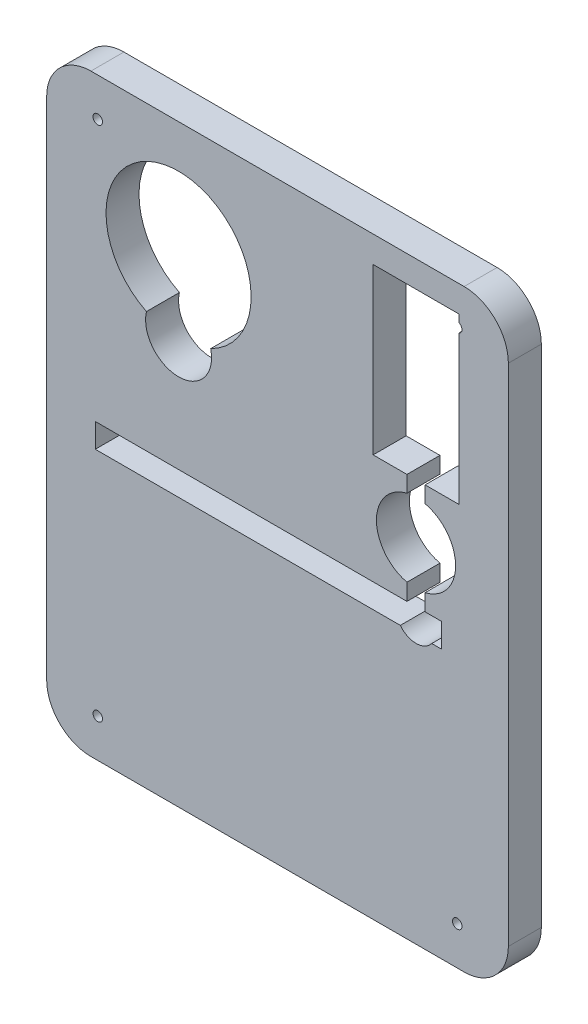
from build123d import *

# Parameters (mm, degrees)
BOSS_EXTRUDE1_DEPTH         = 12.7
CUT_EXTRUDE1_DEPTH          = 13.7
F_27_0_144_DIAMETER_HOLE1_D = 3.6576


with BuildPart() as part:
    # Sketch1 → Boss-Extrude1 (new body)
    with BuildSketch(Plane(origin=(0, 0, 0), x_dir=(0, 1, 0), z_dir=(0, 0, 1))):
        with BuildLine():
            Line((-97.2566, -88.9), (97.2566, -88.9))
            ThreePointArc((97.2566, -88.9), (109.308103714, -83.908103714), (114.3, -71.8566))
            Line((114.3, -71.8566), (114.3, 71.8566))
            ThreePointArc((114.3, 71.8566), (109.308103714, 83.908103714), (97.2566, 88.9))
            Line((97.2566, 88.9), (-97.2566, 88.9))
            ThreePointArc((-97.2566, 88.9), (-109.308103714, 83.908103714), (-114.3, 71.8566))
            Line((-114.3, 71.8566), (-114.3, -71.8566))
            ThreePointArc((-114.3, -71.8566), (-109.308103714, -83.908103714), (-97.2566, -88.9))
        make_face()
    extrude(amount=BOSS_EXTRUDE1_DEPTH)

    # Sketch6 → Cut-Extrude1 (cut, through all)
    with BuildSketch(Plane.XY.offset(12.7)):
        with BuildLine():
            Line((49.8475, 4.691829089), (49.8475, -1.7145))
            Line((49.8475, -1.7145), (-70.1675, -1.7145))
            Line((-70.1675, -1.7145), (-70.1675, -10.9855))
            Line((-70.1675, -10.9855), (47.292145856, -10.9855))
            ThreePointArc((47.292145856, -10.9855), (53.34, -13.97), (59.387854144, -10.9855))
            Line((59.387854144, -10.9855), (63.1825, -10.9855))
            Line((63.1825, -10.9855), (63.1825, -1.7145))
            Line((63.1825, -1.7145), (56.8325, -1.7145))
            Line((56.8325, -1.7145), (56.8325, 4.691829089))
            ThreePointArc((56.8325, 4.691829089), (68.58, 19.52625), (56.8325, 34.360670911))
            Line((56.8325, 34.360670911), (56.8325, 40.64))
            Line((56.8325, 40.64), (69.85, 40.64))
            Line((69.85, 40.64), (69.85, 104.14))
            Line((69.85, 104.14), (36.83, 104.14))
            Line((36.83, 104.14), (36.83, 40.64))
            Line((36.83, 40.64), (49.8475, 40.64))
            Line((49.8475, 40.64), (49.8475, 34.360670911))
            ThreePointArc((49.8475, 34.360670911), (38.1, 19.52625), (49.8475, 4.691829089))
        make_face()
        with BuildLine():
            ThreePointArc((-25.732344403, 44.796363636), (-38.1, 97.79), (-50.467655597, 44.796363636))
            ThreePointArc((-50.467655597, 44.796363636), (-38.1, 29.21), (-25.732344403, 44.796363636))
        make_face()
    extrude(amount=-CUT_EXTRUDE1_DEPTH, mode=Mode.SUBTRACT)

    # #27 (0.144) Diameter Hole1 (through all)
    with Locations(Plane.XY.offset(12.7)):
        with Locations((-69.21913, 99.508615), (-69.21913, -99.508615), (69.21913, -99.508615), (69.21913, 99.508615)):
            Hole(F_27_0_144_DIAMETER_HOLE1_D / 2)


solid = part.part
